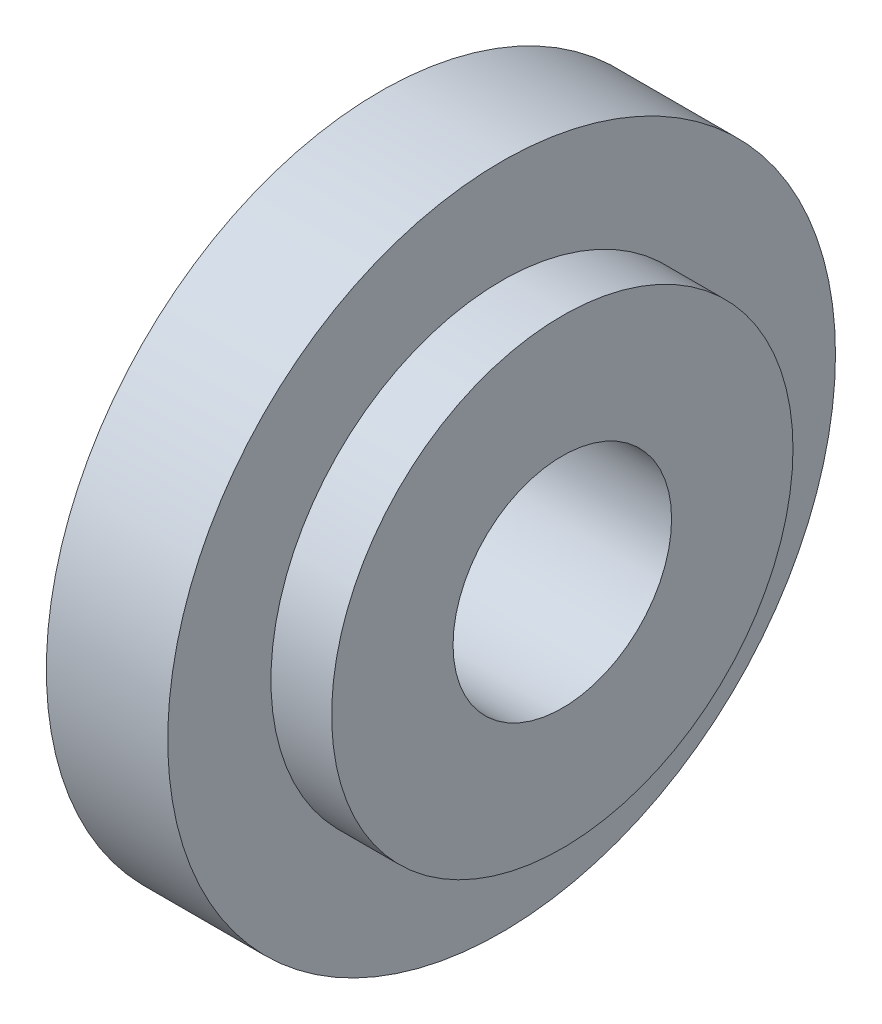
from build123d import *

# Parameters (mm, degrees)
SKETCH1_R           = 5.5
BOSS_EXTRUDE1_DEPTH = 2
SKETCH2_R           = 3.8
BOSS_EXTRUDE2_DEPTH = 1
SKETCH3_R           = 1.8
CUT_EXTRUDE1_DEPTH  = 20


with BuildPart() as part:
    # Sketch1 → Boss-Extrude1 (new body)
    with BuildSketch(Plane(origin=(0, 0, 0), x_dir=(0, 0, -1), z_dir=(1, 0, 0))):
        Circle(SKETCH1_R)
    extrude(amount=BOSS_EXTRUDE1_DEPTH)

    # Sketch2 → Boss-Extrude2 (add)
    with BuildSketch(Plane(origin=(2, 0, 0), x_dir=(0, 0, -1), z_dir=(1, 0, 0))):
        Circle(SKETCH2_R)
    extrude(amount=BOSS_EXTRUDE2_DEPTH)

    # Sketch3 → Cut-Extrude1 (cut)
    with BuildSketch(Plane.ZY):
        Circle(SKETCH3_R)
    extrude(amount=-CUT_EXTRUDE1_DEPTH, mode=Mode.SUBTRACT)


solid = part.part
